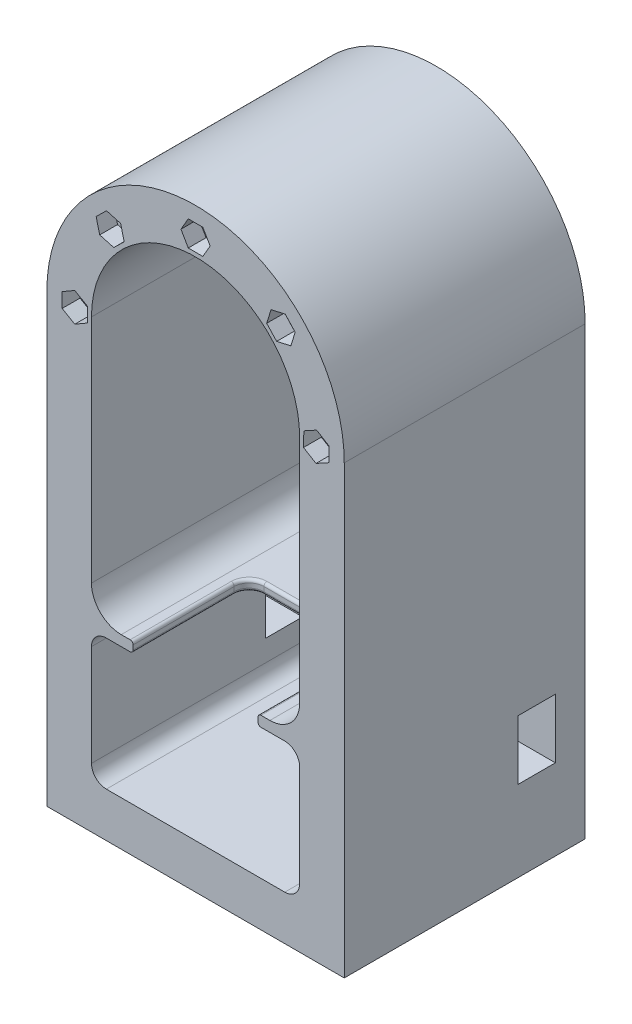
from build123d import *

# Parameters (mm, degrees)
SALIENTE_EXTRUIR1_DEPTH = 81
CORTAR_EXTRUIR1_DEPTH   = 6
CROQUIS3_R              = 2
CORTAR_EXTRUIR2_DEPTH   = 81
CROQUIS4_R              = 4
CORTAR_EXTRUIR4_DEPTH   = 6
CORTAR_EXTRUIR5_DEPTH   = 71
CROQUIS7_R              = 2.75
CORTAR_EXTRUIR6_DEPTH   = 71
CORTAR_EXTRUIR7_DEPTH   = 6
CORTAR_EXTRUIR8_DEPTH   = 6
REDONDEO2_R             = 1
CROQUIS10_R             = 3
CORTAR_EXTRUIR9_DEPTH   = 71
CROQUIS15_W             = 12.5
CROQUIS15_H             = 20
CORTAR_EXTRUIR10_DEPTH  = 100


with BuildPart() as part:
    # Croquis1 → Saliente-Extruir1 (new body)
    with BuildSketch(Plane.XY):
        with BuildLine():
            Line((50, 0), (50, -150))
            Line((50, -150), (0, -150))
            Line((0, -150), (-50, -150))
            Line((-50, -150), (-50, 0))
            ThreePointArc((-50, 0), (0, 50), (50, 0))
        make_face()
        with BuildLine():
            Line((-35, 0), (-35, -77.5))
            ThreePointArc((-35, -77.5), (-32.071067812, -84.571067812), (-25, -87.5))
            Line((-25, -87.5), (25, -87.5))
            ThreePointArc((25, -87.5), (32.071067812, -84.571067812), (35, -77.5))
            Line((35, -77.5), (35, 0))
            ThreePointArc((35, 0), (0, 35), (-35, 0))
        make_face(mode=Mode.SUBTRACT)
    extrude(amount=SALIENTE_EXTRUIR1_DEPTH)

    # Croquis2 → Cortar-Extruir1 (cut)
    with BuildSketch(Plane(origin=(0, 0, 0), x_dir=(-1, 0, 0), z_dir=(0, 0, -1))):
        Polygon((4.907477288, 42.5), (2.453738644, 46.75), (-2.453738644, 46.75), (-4.907477288, 42.5), (-2.453738644, 38.25), (2.453738644, 38.25), align=None)
        Polygon((-42.5, 4.907477288), (-46.75, 2.453738644), (-46.75, -2.453738644), (-42.5, -4.907477288), (-38.25, -2.453738644), (-38.25, 2.453738644), align=None)
        Polygon((42.5, 4.907477288), (38.25, 2.453738644), (38.25, -2.453738644), (42.5, -4.907477288), (46.75, -2.453738644), (46.75, 2.453738644), align=None)
        Polygon((-42.5, -33.842522712), (-46.75, -36.296261356), (-46.75, -41.203738644), (-42.5, -43.657477288), (-38.25, -41.203738644), (-38.25, -36.296261356), align=None)
        Polygon((42.5, -33.842522712), (38.25, -36.296261356), (38.25, -41.203738644), (42.5, -43.657477288), (46.75, -41.203738644), (46.75, -36.296261356), align=None)
        Polygon((-42.5, -130.092522712), (-46.75, -132.546261356), (-46.75, -137.453738644), (-42.5, -139.907477288), (-38.25, -137.453738644), (-38.25, -132.546261356), align=None)
        Polygon((42.5, -139.907477288), (46.75, -137.453738644), (46.75, -132.546261356), (42.5, -130.092522712), (38.25, -132.546261356), (38.25, -137.453738644), align=None)
    extrude(amount=-CORTAR_EXTRUIR1_DEPTH, mode=Mode.SUBTRACT)

    # Croquis3 → Cortar-Extruir2 (cut)
    with BuildSketch(Plane.XY.offset(81)):
        with Locations((-15.5, -97.5)):
            Circle(CROQUIS3_R)
        with Locations((15.5, -97.5)):
            Circle(CROQUIS3_R)
        with Locations((15.5, -128.5)):
            Circle(CROQUIS3_R)
        with Locations((-15.5, -128.5)):
            Circle(CROQUIS3_R)
    extrude(amount=-CORTAR_EXTRUIR2_DEPTH, mode=Mode.SUBTRACT)

    # Croquis4 → Cortar-Extruir4 (cut)
    with BuildSketch(Plane(origin=(0, 0, 0), x_dir=(-1, 0, 0), z_dir=(0, 0, -1))):
        with Locations((-15.5, -97.5)):
            Circle(CROQUIS4_R)
        with Locations((15.5, -97.5)):
            Circle(CROQUIS4_R)
        with Locations((-15.5, -128.5)):
            Circle(CROQUIS4_R)
        with Locations((15.5, -128.5)):
            Circle(CROQUIS4_R)
    extrude(amount=-CORTAR_EXTRUIR4_DEPTH, mode=Mode.SUBTRACT)

    # Croquis6 → Cortar-Extruir5 (cut)
    with BuildSketch(Plane.XY.offset(81)):
        with BuildLine():
            Line((-30, -91), (30, -91))
            ThreePointArc((30, -91), (33.535533906, -92.464466094), (35, -96))
            Line((35, -96), (35, -130))
            ThreePointArc((35, -130), (33.535533906, -133.535533906), (30, -135))
            Line((30, -135), (-30, -135))
            ThreePointArc((-30, -135), (-33.535533906, -133.535533906), (-35, -130))
            Line((-35, -130), (-35, -96))
            ThreePointArc((-35, -96), (-33.535533906, -92.464466094), (-30, -91))
        make_face()
    extrude(amount=-CORTAR_EXTRUIR5_DEPTH, mode=Mode.SUBTRACT)

    # Croquis7 → Cortar-Extruir6 (cut)
    with BuildSketch(Plane.XY.offset(81)):
        with Locations((0, 40.605)):
            Circle(CROQUIS7_R)
        with Locations((28.71207085, 28.71207085)):
            Circle(CROQUIS7_R)
        with Locations((40.605, 0)):
            Circle(CROQUIS7_R)
        with Locations((28.71207085, -28.71207085)):
            Circle(CROQUIS7_R)
        with Locations((0, -40.605)):
            Circle(CROQUIS7_R)
        with Locations((-28.71207085, -28.71207085)):
            Circle(CROQUIS7_R)
        with Locations((-40.605, 0)):
            Circle(CROQUIS7_R)
        with Locations((-28.71207085, 28.71207085)):
            Circle(CROQUIS7_R)
    extrude(amount=-CORTAR_EXTRUIR6_DEPTH, mode=Mode.SUBTRACT)

    # Croquis8 → Cortar-Extruir7 (cut)
    with BuildSketch(Plane.XY.offset(81)):
        Polygon((4.907477288, 40.605), (2.453738644, 44.855), (-2.453738644, 44.855), (-4.907477288, 40.605), (-2.453738644, 36.355), (2.453738644, 36.355), align=None)
        Polygon((-23.987281715, 27.385533641), (-25.200861361, 32.140589664), (-29.925650495, 33.467126873), (-33.436859985, 30.038608059), (-32.223280339, 25.283552036), (-27.498491205, 23.957014828), align=None)
        Polygon((32.049942164, 25.114578887), (33.496525937, 29.804006221), (30.158654623, 33.401498184), (25.374199536, 32.309562813), (23.927615763, 27.62013548), (27.265487077, 24.022643516), align=None)
        Polygon((-40.605, -4.907477288), (-36.355, -2.453738644), (-36.355, 2.453738644), (-40.605, 4.907477288), (-44.855, 2.453738644), (-44.855, -2.453738644), align=None)
        Polygon((44.801667212, -2.543878465), (44.906396981, 2.362481184), (40.709729769, 4.906359649), (36.408332788, 2.543878465), (36.303603019, -2.362481184), (40.500270231, -4.906359649), align=None)
    extrude(amount=-CORTAR_EXTRUIR7_DEPTH, mode=Mode.SUBTRACT)

    # Croquis9 → Cortar-Extruir8 (cut)
    with BuildSketch(Plane(origin=(0, -87.5, 0), x_dir=(1, 0, 0), z_dir=(0, 1, 0))):
        with BuildLine():
            Line((-21, -120), (21, -120))
            Line((21, -120), (21, -47))
            ThreePointArc((21, -47), (19.535533906, -43.464466094), (16, -42))
            Line((16, -42), (-16, -42))
            ThreePointArc((-16, -42), (-19.535533906, -43.464466094), (-21, -47))
            Line((-21, -47), (-21, -120))
        make_face()
    extrude(amount=-CORTAR_EXTRUIR8_DEPTH, mode=Mode.SUBTRACT)

    # Redondeo2
    redondeo2_edges = [part.edges().sort_by_distance(p)[0] for p in [
        (21, -91, 64),
        (19.535533906, -91, 43.464466094),
        (0, -91, 42),
        (-19.535533906, -91, 43.464466094),
        (-21, -91, 64),
        (-21, -87.5, 64),
        (21, -87.5, 64),
        (19.535533906, -87.5, 43.464466094),
        (0, -87.5, 42),
        (-19.535533906, -87.5, 43.464466094),
    ]]
    fillet(redondeo2_edges, radius=REDONDEO2_R)

    # Croquis10 → Cortar-Extruir9 (cut)
    with BuildSketch(Plane(origin=(0, 0, 0), x_dir=(-1, 0, 0), z_dir=(0, 0, -1))):
        with Locations((0, 42.5)):
            Circle(CROQUIS10_R)
        with Locations((-42.5, 0)):
            Circle(CROQUIS10_R)
        with Locations((42.5, 0)):
            Circle(CROQUIS10_R)
        with Locations((42.5, -38.75)):
            Circle(CROQUIS10_R)
        with Locations((-42.5, -38.75)):
            Circle(CROQUIS10_R)
        with Locations((-42.5, -135)):
            Circle(CROQUIS10_R)
        with Locations((42.5, -135)):
            Circle(CROQUIS10_R)
    extrude(amount=-CORTAR_EXTRUIR9_DEPTH, mode=Mode.SUBTRACT)

    # Croquis15 → Cortar-Extruir10 (cut)
    with BuildSketch(Plane(origin=(50, 0, 0), x_dir=(0, 0, -1), z_dir=(1, 0, 0))):
        with Locations((-16.25, -112.839909006)):
            Rectangle(CROQUIS15_W, CROQUIS15_H)
    extrude(amount=-CORTAR_EXTRUIR10_DEPTH, mode=Mode.SUBTRACT)


solid = part.part
